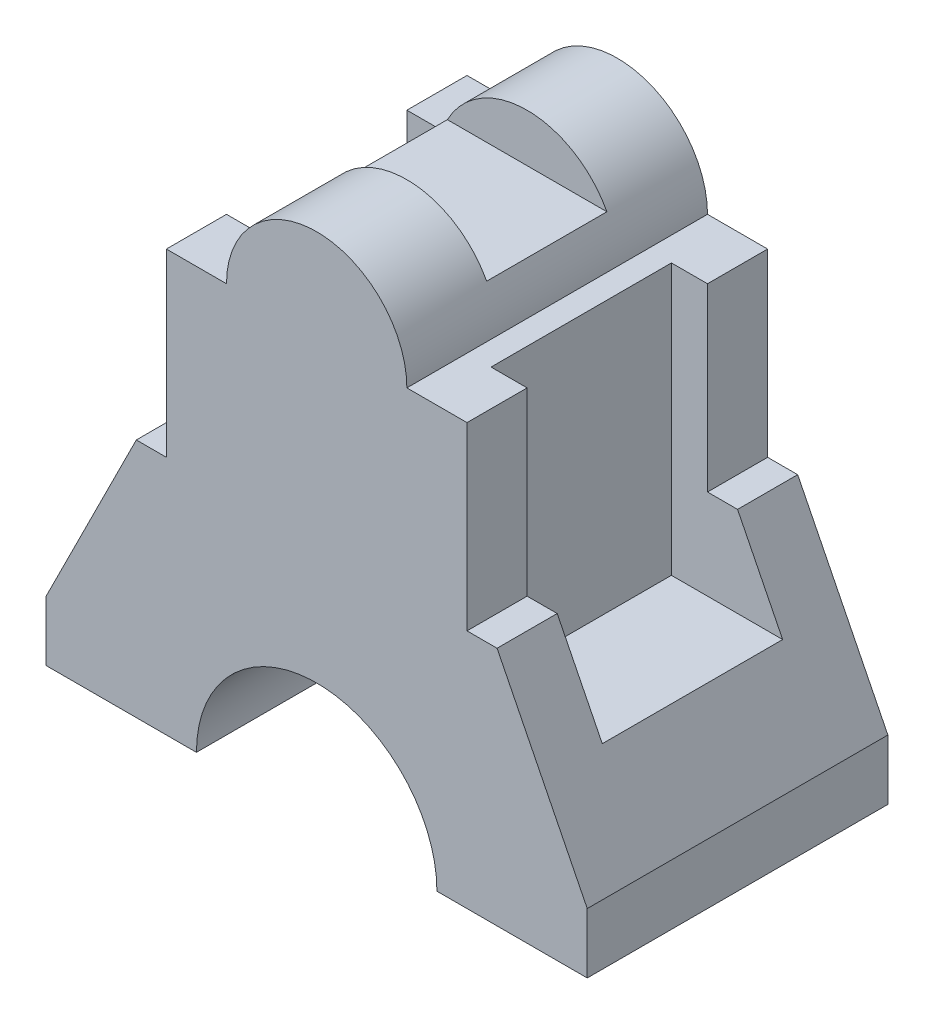
from build123d import *

# Parameters (mm, degrees)
BOSS_EXTRUDE2_DEPTH = 25
SKETCH6_W           = 20
SKETCH6_H           = 8
CUT_EXTRUDE1_DEPTH  = 25
CUT_EXTRUDE2_DEPTH  = 51
SKETCH11_W          = 26
SKETCH11_H          = 30
CUT_EXTRUDE3_DEPTH  = 45


with BuildPart() as part:
    # Sketch3 → Boss-Extrude2 (new body, symmetric)
    with BuildSketch(Plane.XY):
        with BuildLine():
            Line((0, 85), (0, 70))
            Line((0, 70), (15, 70))
            ThreePointArc((15, 70), (10.606601718, 80.606601718), (0, 85))
        make_face()
        with BuildLine():
            Line((-15, 70), (0, 70))
            Line((0, 70), (0, 85))
            ThreePointArc((0, 85), (-10.606601718, 80.606601718), (-15, 70))
        make_face()
        Polygon((0, 70), (0, 40), (25, 40), (25, 70), (15, 70), align=None)
        Polygon((-45, 0), (0, 0), (0, 40), (-25, 40), (-30, 40), (-45, 10), align=None)
        Polygon((0, 0), (45, 0), (45, 10), (30, 40), (25, 40), (0, 40), align=None)
        Polygon((-25, 40), (0, 40), (0, 70), (-15, 70), (-25, 70), align=None)
    extrude(amount=BOSS_EXTRUDE2_DEPTH, both=True)

    # Sketch6 → Cut-Extrude1 (cut, symmetric)
    with BuildSketch(Plane(origin=(0, 0, 0), x_dir=(0, 0, -1), z_dir=(1, 0, 0))):
        with Locations((0, 81)):
            Rectangle(SKETCH6_W, SKETCH6_H)
    extrude(amount=CUT_EXTRUDE1_DEPTH, both=True, mode=Mode.SUBTRACT)

    # Sketch7 → Cut-Extrude2 (cut, through all)
    with BuildSketch(Plane(origin=(0, 0, -25), x_dir=(-1, 0, 0), z_dir=(0, 0, -1))):
        with BuildLine():
            Line((-20, 0), (20, 0))
            ThreePointArc((20, 0), (0, 20), (-20, 0))
        make_face()
    extrude(amount=-CUT_EXTRUDE2_DEPTH, mode=Mode.SUBTRACT)

    # Sketch11 → Cut-Extrude3 (cut)
    with BuildSketch(Plane(origin=(0, 70, 0), x_dir=(1, 0, 0), z_dir=(0, 1, 0))):
        with Locations((-32, 0)):
            Rectangle(SKETCH11_W, SKETCH11_H)
        with Locations((32, 0)):
            Rectangle(SKETCH11_W, SKETCH11_H)
    extrude(amount=-CUT_EXTRUDE3_DEPTH, mode=Mode.SUBTRACT)


solid = part.part
